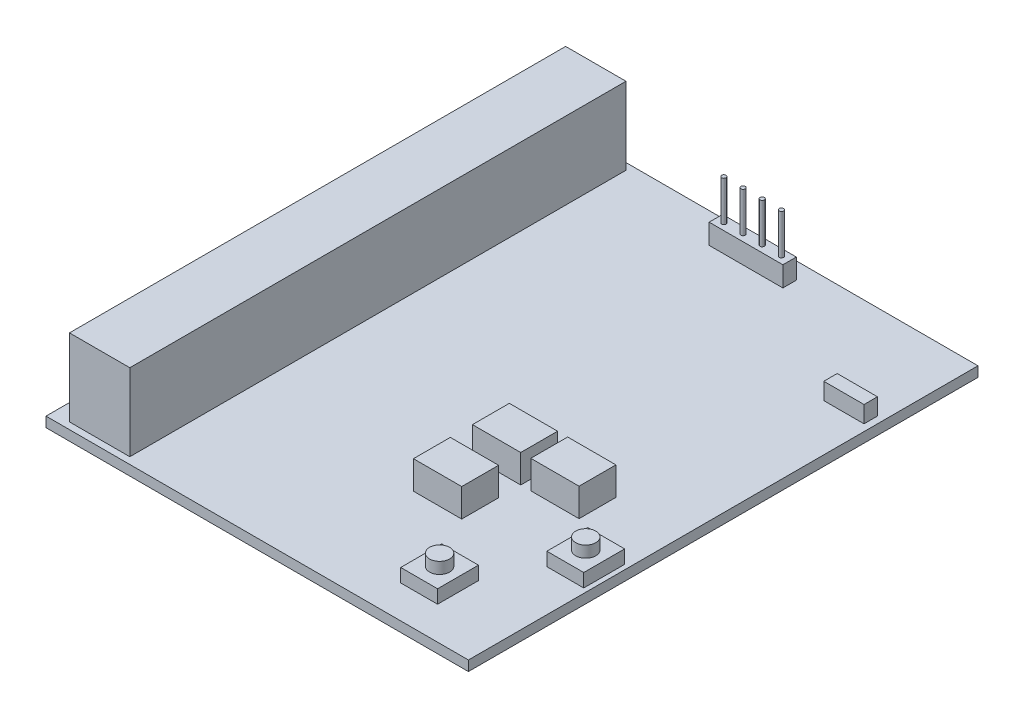
from build123d import *

# Parameters (mm, degrees)
SKETCH1_W            = 63
SKETCH1_H            = 76
BOSS_EXTRUDE1_DEPTH  = 1.5
SKETCH2_W            = 9
SKETCH2_H            = 74
BOSS_EXTRUDE2_DEPTH  = 11.5
SKETCH3_W            = 7
SKETCH3_H            = 8
BOSS_EXTRUDE3_DEPTH  = 3.5
SKETCH4_W            = 11
SKETCH4_H            = 2
BOSS_EXTRUDE4_DEPTH  = 3
SKETCH5_R            = 0.325
BOSS_EXTRUDE5_DEPTH  = 6
SKETCH6_W            = 6
SKETCH6_H            = 2
BOSS_EXTRUDE6_DEPTH  = 2.5
SKETCH8_W            = 7.2
SKETCH8_H            = 5.5
BOSS_EXTRUDE8_DEPTH  = 4.2
SKETCH9_W            = 5.5
SKETCH9_H            = 6.1
BOSS_EXTRUDE9_DEPTH  = 2
SKETCH10_R           = 1.5
BOSS_EXTRUDE10_DEPTH = 1.7
SKETCH11_W           = 5.5
SKETCH11_H           = 6.1
BOSS_EXTRUDE11_DEPTH = 2
SKETCH12_R           = 1.5
BOSS_EXTRUDE12_DEPTH = 1.7


with BuildPart() as part:
    # Sketch1 → Boss-Extrude1 (new body)
    with BuildSketch(Plane(origin=(0, 0, 0), x_dir=(1, 0, 0), z_dir=(0, 1, 0))):
        with Locations((31.5, 38)):
            Rectangle(SKETCH1_W, SKETCH1_H)
    extrude(amount=BOSS_EXTRUDE1_DEPTH)

    # Sketch2 → Boss-Extrude2 (add)
    with BuildSketch(Plane(origin=(0, 1.5, 0), x_dir=(1, 0, 0), z_dir=(0, 1, 0))):
        with Locations((7, 38)):
            Rectangle(SKETCH2_W, SKETCH2_H)
    extrude(amount=BOSS_EXTRUDE2_DEPTH)

    # Sketch3 → Boss-Extrude3 (add)
    with BuildSketch(Plane.XZ):
        with Locations((12.5, -19)):
            Rectangle(SKETCH3_W, SKETCH3_H)
        with Locations((12.5, -38)):
            Rectangle(SKETCH3_W, SKETCH3_H)
        with Locations((12.5, -60)):
            Rectangle(SKETCH3_W, SKETCH3_H)
    extrude(amount=BOSS_EXTRUDE3_DEPTH)

    # Sketch4 → Boss-Extrude4 (add)
    with BuildSketch(Plane(origin=(0, 1.5, 0), x_dir=(1, 0, 0), z_dir=(0, 1, 0))):
        with Locations((32.9, 72.5)):
            Rectangle(SKETCH4_W, SKETCH4_H)
    extrude(amount=BOSS_EXTRUDE4_DEPTH)

    # Sketch5 → Boss-Extrude5 (add)
    with BuildSketch(Plane(origin=(0, 4.5, 0), x_dir=(1, 0, 0), z_dir=(0, 1, 0))):
        with Locations((28.6, 72.5)):
            Circle(SKETCH5_R)
        with Locations((31.46, 72.5)):
            Circle(SKETCH5_R)
        with Locations((34.32, 72.5)):
            Circle(SKETCH5_R)
        with Locations((37.18, 72.5)):
            Circle(SKETCH5_R)
    extrude(amount=BOSS_EXTRUDE5_DEPTH)

    # Sketch6 → Boss-Extrude6 (add)
    with BuildSketch(Plane(origin=(0, 1.5, 0), x_dir=(1, 0, 0), z_dir=(0, 1, 0))):
        with Locations((59, 61)):
            Rectangle(SKETCH6_W, SKETCH6_H)
    extrude(amount=BOSS_EXTRUDE6_DEPTH)

    # Sketch8 → Boss-Extrude8 (add)
    with BuildSketch(Plane(origin=(0, 1.5, 0), x_dir=(1, 0, 0), z_dir=(0, 1, 0))):
        with Locations((40.7, 29.25)):
            Rectangle(SKETCH8_W, SKETCH8_H)
        with Locations((49.4, 29.25)):
            Rectangle(SKETCH8_W, SKETCH8_H)
        with Locations((40.7, 20.45)):
            Rectangle(SKETCH8_W, SKETCH8_H)
    extrude(amount=BOSS_EXTRUDE8_DEPTH)

    # Sketch9 → Boss-Extrude9 (add)
    with BuildSketch(Plane(origin=(0, 1.5, 0), x_dir=(1, 0, 0), z_dir=(0, 1, 0))):
        with Locations((59.55, 20.95)):
            Rectangle(SKETCH9_W, SKETCH9_H)
    extrude(amount=BOSS_EXTRUDE9_DEPTH)

    # Sketch10 → Boss-Extrude10 (add)
    with BuildSketch(Plane(origin=(0, 3.5, 0), x_dir=(1, 0, 0), z_dir=(0, 1, 0))):
        with Locations((59.55, 20.95)):
            Circle(SKETCH10_R)
    extrude(amount=BOSS_EXTRUDE10_DEPTH)

    # Sketch11 → Boss-Extrude11 (add)
    with BuildSketch(Plane(origin=(0, 1.5, 0), x_dir=(1, 0, 0), z_dir=(0, 1, 0))):
        with Locations((50.75, 7.95)):
            Rectangle(SKETCH11_W, SKETCH11_H)
    extrude(amount=BOSS_EXTRUDE11_DEPTH)

    # Sketch12 → Boss-Extrude12 (add)
    with BuildSketch(Plane(origin=(0, 3.5, 0), x_dir=(1, 0, 0), z_dir=(0, 1, 0))):
        with Locations((50.75, 7.95)):
            Circle(SKETCH12_R)
    extrude(amount=BOSS_EXTRUDE12_DEPTH)


solid = part.part
